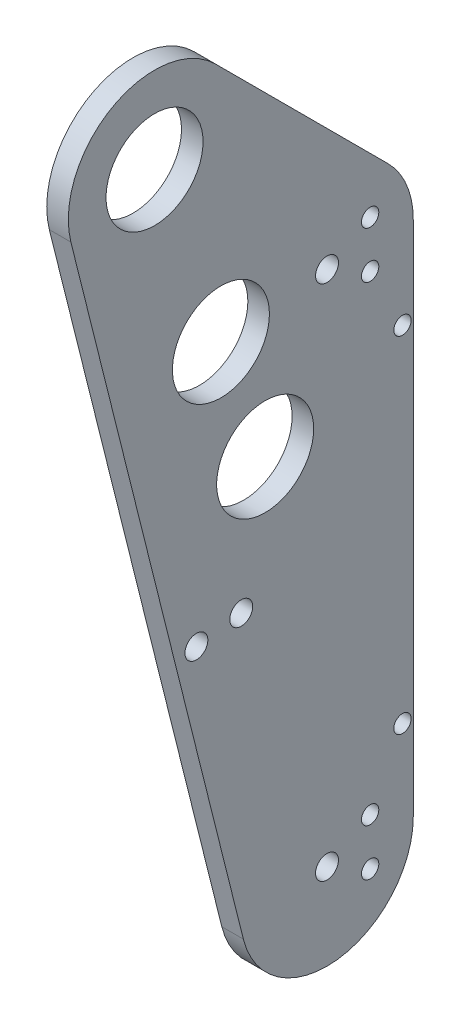
from build123d import *

# Parameters (mm, degrees)
BOSS_EXTRUDE1_DEPTH     = 6.35
F_1_1_DIAMETER_HOLE1_D  = 28.575
F_1_4_CLEARANCE_HOLE1_D = 6.7564
F_1_4_20_TAPPED_HOLE1_D = 5.1054
F_1_4_CLEARANCE_HOLE2_D = 6.7564
F_10_CLEARANCE_HOLE1_D  = 5.1054


with BuildPart() as part:
    # Sketch2 → Boss-Extrude1 (new body)
    with BuildSketch(Plane(origin=(0, 0, 0), x_dir=(0, 0, -1), z_dir=(1, 0, 0))):
        with BuildLine():
            Line((68.760512242, -32.839487758), (17.960512242, 17.960512242))
            ThreePointArc((17.960512242, 17.960512242), (-12.514549901, 22.103077632), (-24.641619504, -6.160404876))
            Line((-24.641619504, -6.160404876), (26.158380496, -209.360404876))
            ThreePointArc((26.158380496, -209.360404876), (53.903454898, -228.40969194), (76.2, -203.2))
            Line((76.2, -203.2), (76.2, -50.8))
            ThreePointArc((76.2, -50.8), (74.266540126, -41.079840818), (68.760512242, -32.839487758))
        make_face()
    extrude(amount=BOSS_EXTRUDE1_DEPTH)

    # 1 (1) Diameter Hole1 (through all)
    with Locations(Plane(origin=(6.35, 0, 0), x_dir=(0, 0, -1), z_dir=(1, 0, 0))):
        with Locations((0, 0), (19.546451191, -53.703433278), (32.577418652, -89.50572213)):
            Hole(F_1_1_DIAMETER_HOLE1_D / 2)

    # 1/4 Clearance Hole1 (through all)
    with Locations(Plane(origin=(6.35, 0, 0), x_dir=(0, 0, -1), z_dir=(1, 0, 0))):
        with Locations((50.8, -50.8), (50.8, -203.2), (12.320809752, -127.828401175)):
            Hole(F_1_4_CLEARANCE_HOLE1_D / 2)

    # 1/4-20 Tapped Hole1 (through all)
    with Locations(Plane.ZY):
        with Locations((-63.5, -57.7088), (-63.5, -43.8912), (-63.5, -210.1088), (-63.5, -196.2912)):
            Hole(F_1_4_20_TAPPED_HOLE1_D / 2)

    # 1/4 Clearance Hole2 (through all)
    with Locations(Plane.ZY):
        with Locations((-25.535413776, -125.85644657)):
            Hole(F_1_4_CLEARANCE_HOLE2_D / 2)

    # #10 Clearance Hole1 (through all)
    with Locations(Plane.ZY):
        with Locations((-73.025, -76.2), (-73.025, -177.8)):
            Hole(F_10_CLEARANCE_HOLE1_D / 2)


solid = part.part
